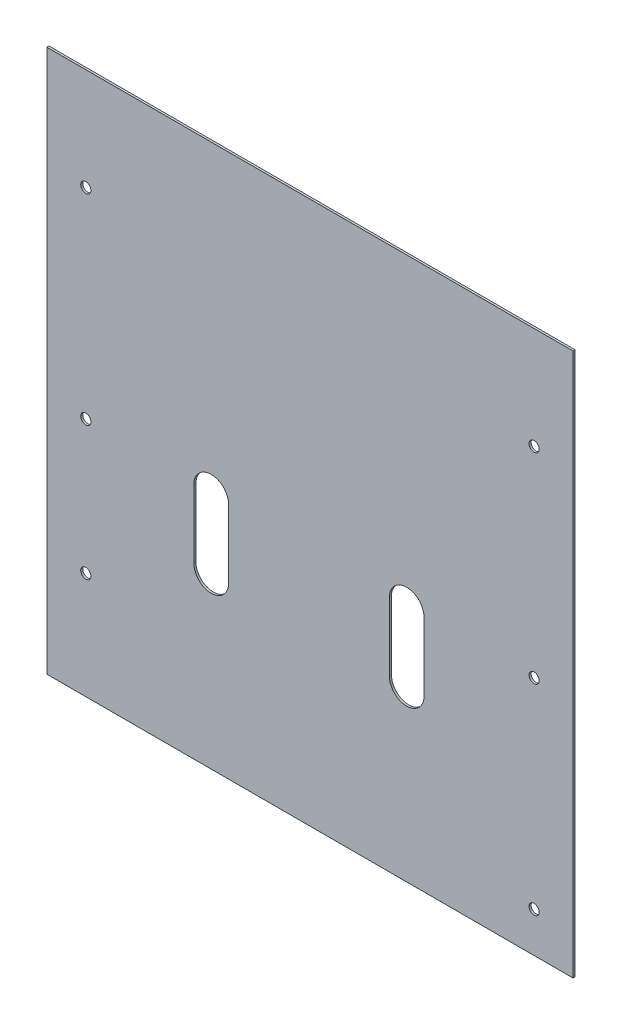
from build123d import *

# Parameters (mm, degrees)
SKETCH1_W                             = 196.85
SKETCH1_H                             = 203.2
BOSS_EXTRUDE1_DEPTH                   = 0.7747
CUT_EXTRUDE7_DEPTH                    = 1.7747
SKETCH4_W                             = 196.85
SKETCH4_H                             = 0.6096
BOSS_EXTRUDE2_DEPTH                   = 12
SKETCH14_W                            = 196.85
SKETCH14_H                            = 11.938
BOSS_EXTRUDE3_DEPTH                   = 0.7747
SKETCH13_W                            = 196.85
SKETCH13_H                            = 0.6096
CUT_EXTRUDE9_DEPTH                    = 12
CSK_FOR_M3_FLAT_HEAD_MACHINE_SCREW3_D = 3.81
SKETCH19_W                            = 182.676330849
SKETCH19_H                            = 33.741187375
BOSS_EXTRUDE4_DEPTH                   = 0.7747
SKETCH21_W                            = 22.718000829
SKETCH21_H                            = 22.312299049
SKETCH21_W_2                          = 21.538835619
SKETCH21_H_2                          = 16.643270878
BOSS_EXTRUDE5_DEPTH                   = 0.7747
SKETCH22_W                            = 13.90531837
SKETCH22_H                            = 14.215216999
SKETCH22_W_2                          = 12.509578485
SKETCH22_H_2                          = 9.075576548
BOSS_EXTRUDE6_DEPTH                   = 0.7747


with BuildPart() as part:
    # Sketch1 → Boss-Extrude1 (new body)
    with BuildSketch(Plane(origin=(0, 0, 0), x_dir=(1, 0, 0), z_dir=(0, 0, -1))):
        with Locations((-104.775, 135.4)):
            Rectangle(SKETCH1_W, SKETCH1_H)
    extrude(amount=BOSS_EXTRUDE1_DEPTH)

    # Sketch2 → Cut-Extrude7 (cut, through all)
    with BuildSketch(Plane(origin=(0, 0, -0.7747), x_dir=(1, 0, 0), z_dir=(0, 0, -1))):
        with BuildLine():
            Line((-135.221253236, 173.5), (-135.221253236, 148))
            ThreePointArc((-135.221253236, 148), (-141.721253236, 141.5), (-148.221253236, 148))
            Line((-148.221253236, 148), (-148.221253236, 173.5))
            ThreePointArc((-148.221253236, 173.5), (-141.721253236, 180), (-135.221253236, 173.5))
        make_face()
        with BuildLine():
            Line((-62.069253236, 173.5), (-62.069253236, 148))
            ThreePointArc((-62.069253236, 148), (-68.569253236, 141.5), (-75.069253236, 148))
            Line((-75.069253236, 148), (-75.069253236, 173.5))
            ThreePointArc((-75.069253236, 173.5), (-68.569253236, 180), (-62.069253236, 173.5))
        make_face()
    extrude(amount=-CUT_EXTRUDE7_DEPTH, mode=Mode.SUBTRACT)

    # Sketch4 → Boss-Extrude2 (add)
    with BuildSketch(Plane.XY):
        with Locations((-104.775, -34.1048)):
            Rectangle(SKETCH4_W, SKETCH4_H)
    extrude(amount=BOSS_EXTRUDE2_DEPTH)

    # Sketch14 → Boss-Extrude3 (add)
    with BuildSketch(Plane.XY):
        with Locations((-104.775, -53.935004147)):
            Rectangle(SKETCH14_W, SKETCH14_H)
    extrude(amount=-BOSS_EXTRUDE3_DEPTH)

    # Sketch13 → Cut-Extrude9 (cut)
    with BuildSketch(Plane.XY.offset(12)):
        with Locations((-104.775, -34.1048)):
            Rectangle(SKETCH13_W, SKETCH13_H)
    extrude(amount=-CUT_EXTRUDE9_DEPTH, mode=Mode.SUBTRACT)

    # CSK for M3 Flat Head Machine Screw3 (through all)
    with Locations(Plane.XY):
        with Locations((-188.645, -72), (-188.645, -222), (-188.645, -197), (-188.645, -172), (-188.645, -147), (-188.645, -122), (-188.645, -97)):
            csk_for_m3_flat_head_machine_screw3 = Hole(CSK_FOR_M3_FLAT_HEAD_MACHINE_SCREW3_D / 2)

    # Mirror1: CSK for M3 Flat Head Machine Screw3 across plane
    add(csk_for_m3_flat_head_machine_screw3.mirror(Plane(origin=(-104.775, 0, 0), x_dir=(0, 0, 1), z_dir=(1, 0, 0))), mode=Mode.SUBTRACT)

    # Sketch19 → Boss-Extrude4 (add)
    with BuildSketch(Plane(origin=(0, 0, -0.7747), x_dir=(-1, 0, 0), z_dir=(0, 0, -1))):
        with Locations((101.266706015, -109.837466763)):
            Rectangle(SKETCH19_W, SKETCH19_H)
    extrude(amount=-BOSS_EXTRUDE4_DEPTH)

    # Sketch21 → Boss-Extrude5 (add)
    with BuildSketch(Plane(origin=(0, 0, -0.7747), x_dir=(-1, 0, 0), z_dir=(0, 0, -1))):
        with Locations((185.571692861, -170.919383368)):
            Rectangle(SKETCH21_W, SKETCH21_H)
        with Locations((24.271371833, -173.753897453)):
            Rectangle(SKETCH21_W_2, SKETCH21_H_2)
    extrude(amount=-BOSS_EXTRUDE5_DEPTH)

    # Sketch22 → Boss-Extrude6 (add)
    with BuildSketch(Plane.XY):
        with Locations((-189.313880795, -220.883843828)):
            Rectangle(SKETCH22_W, SKETCH22_H)
        with Locations((-23.670028487, -197.876391374)):
            Rectangle(SKETCH22_W_2, SKETCH22_H_2)
    extrude(amount=-BOSS_EXTRUDE6_DEPTH)


solid = part.part
